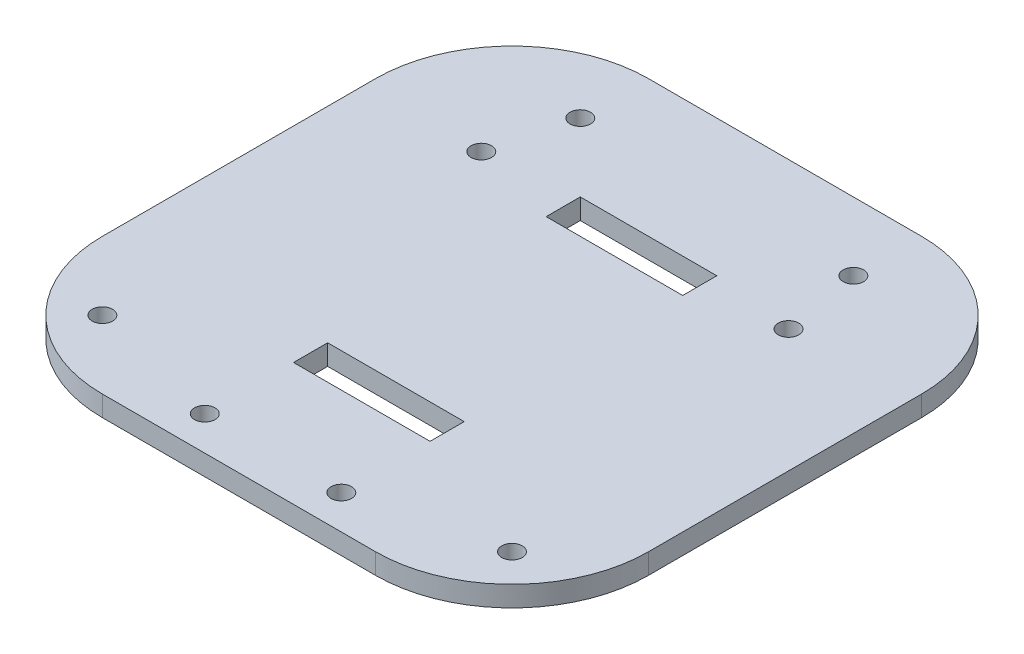
from build123d import *

# Parameters (mm, degrees)
SKETCH3_W           = 80
SKETCH3_H           = 80
BOSS_EXTRUDE1_DEPTH = 3
FILLET3_R           = 20
FILLET4_R           = 20
FILLET5_R           = 20
FILLET6_R           = 20
SKETCH6_R           = 1.5
CUT_EXTRUDE2_DEPTH  = 3
SKETCH9_R           = 1.5
CUT_EXTRUDE3_DEPTH  = 3
SKETCH12_R          = 1.5
CUT_EXTRUDE6_DEPTH  = 3
SKETCH13_R          = 1.5
CUT_EXTRUDE7_DEPTH  = 3
SKETCH14_W          = 20
SKETCH14_H          = 5
CUT_EXTRUDE8_DEPTH  = 10


with BuildPart() as part:
    # Sketch3 → Boss-Extrude1 (new body)
    with BuildSketch(Plane(origin=(0, 0, 0), x_dir=(1, 0, 0), z_dir=(0, 1, 0))):
        with Locations((40, 40)):
            Rectangle(SKETCH3_W, SKETCH3_H)
    extrude(amount=BOSS_EXTRUDE1_DEPTH)

    # Fillet3
    fillet3_edges = [part.edges().sort_by_distance(p)[0] for p in [
        (0, 1.5, -80),
    ]]
    fillet(fillet3_edges, radius=FILLET3_R)

    # Fillet4
    fillet4_edges = [part.edges().sort_by_distance(p)[0] for p in [
        (80, 1.5, -80),
    ]]
    fillet(fillet4_edges, radius=FILLET4_R)

    # Fillet5
    fillet5_edges = [part.edges().sort_by_distance(p)[0] for p in [
        (80, 1.5, 0),
    ]]
    fillet(fillet5_edges, radius=FILLET5_R)

    # Fillet6
    fillet6_edges = [part.edges().sort_by_distance(p)[0] for p in [
        (0, 1.5, 0),
    ]]
    fillet(fillet6_edges, radius=FILLET6_R)

    # Sketch6 → Cut-Extrude2 (cut)
    with BuildSketch(Plane(origin=(0, 3, 0), x_dir=(1, 0, 0), z_dir=(0, 1, 0))):
        with Locations((17, 58.5)):
            Circle(SKETCH6_R)
        with Locations((62, 58.5)):
            Circle(SKETCH6_R)
    extrude(amount=-CUT_EXTRUDE2_DEPTH, mode=Mode.SUBTRACT)

    # Sketch9 → Cut-Extrude3 (cut)
    with BuildSketch(Plane(origin=(0, 3, 0), x_dir=(1, 0, 0), z_dir=(0, 1, 0))):
        with Locations((70, 10)):
            Circle(SKETCH9_R)
        with Locations((10, 10)):
            Circle(SKETCH9_R)
    extrude(amount=-CUT_EXTRUDE3_DEPTH, mode=Mode.SUBTRACT)

    # Sketch12 → Cut-Extrude6 (cut)
    with BuildSketch(Plane(origin=(0, 3, 0), x_dir=(1, 0, 0), z_dir=(0, 1, 0))):
        with Locations((30, 5)):
            Circle(SKETCH12_R)
        with Locations((50, 5)):
            Circle(SKETCH12_R)
    extrude(amount=-CUT_EXTRUDE6_DEPTH, mode=Mode.SUBTRACT)

    # Sketch13 → Cut-Extrude7 (cut)
    with BuildSketch(Plane(origin=(0, 3, 0), x_dir=(1, 0, 0), z_dir=(0, 1, 0))):
        with Locations((20, 70)):
            Circle(SKETCH13_R)
        with Locations((60, 70)):
            Circle(SKETCH13_R)
    extrude(amount=-CUT_EXTRUDE7_DEPTH, mode=Mode.SUBTRACT)

    # Sketch14 → Cut-Extrude8 (cut)
    with BuildSketch(Plane(origin=(0, 3, 0), x_dir=(1, 0, 0), z_dir=(0, 1, 0))):
        with Locations((40, 57.5)):
            Rectangle(SKETCH14_W, SKETCH14_H)
        with Locations((40, 20.5)):
            Rectangle(SKETCH14_W, SKETCH14_H)
    extrude(amount=-CUT_EXTRUDE8_DEPTH, mode=Mode.SUBTRACT)


solid = part.part
